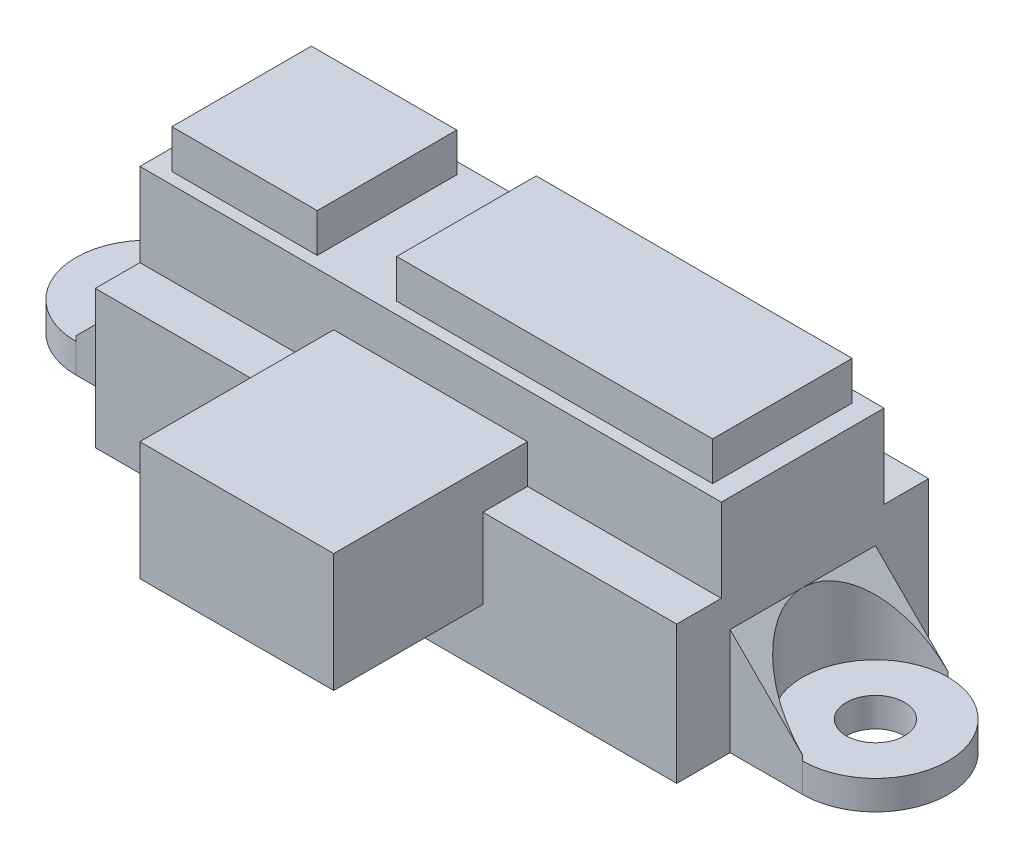
from build123d import *

# Parameters (mm, degrees)
SKETCH1_W            = 30
SKETCH1_H            = 13
BOTTOMPLATEAU_DEPTH  = 7.12
SKETCH3_R            = 1.5
SCREWSOCKETS_DEPTH   = 1.5
SKETCH4_W            = 30
SKETCH4_H            = 8.4
TOPPLATEAU_DEPTH     = 4.3
SKETCH5_W            = 7.5
SKETCH5_H            = 7.2
SKETCH5_W_2          = 16.3
SENSORSOCKETS_DEPTH  = 2
EXTRUDEDSLANTS_DEPTH = 4
F_45SLANTS_DEPTH     = 7.5
CONNECTION_W         = 10
CONNECTION_H         = 6.12
BOSS_EXTRUDE6_DEPTH  = 10


with BuildPart() as part:
    # Sketch1 → BottomPlateau (new body)
    with BuildSketch(Plane(origin=(0, 0, 0), x_dir=(1, 0, 0), z_dir=(0, 1, 0))):
        Rectangle(SKETCH1_W, SKETCH1_H)
    extrude(amount=BOTTOMPLATEAU_DEPTH)

    # Sketch3 → ScrewSockets (add)
    with BuildSketch(Plane.XZ):
        with BuildLine():
            Line((-18.75, 3.75), (-15, 3.75))
            Line((-15, 3.75), (-15, -3.75))
            Line((-15, -3.75), (-18.75, -3.75))
            ThreePointArc((-18.75, -3.75), (-22.5, 0), (-18.75, 3.75))
        make_face()
        with Locations((-18.75, 0)):
            Circle(SKETCH3_R, mode=Mode.SUBTRACT)
        with BuildLine():
            Line((18.75, 3.75), (15, 3.75))
            Line((15, 3.75), (15, -3.75))
            Line((15, -3.75), (18.75, -3.75))
            ThreePointArc((18.75, -3.75), (22.5, 0), (18.75, 3.75))
        make_face()
        with Locations((18.75, 0)):
            Circle(SKETCH3_R, mode=Mode.SUBTRACT)
    extrude(amount=-SCREWSOCKETS_DEPTH)

    # Sketch4 → TopPlateau (add)
    with BuildSketch(Plane(origin=(0, 7.12, 0), x_dir=(1, 0, 0), z_dir=(0, 1, 0))):
        Rectangle(SKETCH4_W, SKETCH4_H)
    extrude(amount=TOPPLATEAU_DEPTH)

    # Sketch5 → SensorSockets (add)
    with BuildSketch(Plane(origin=(0, 11.42, 0), x_dir=(1, 0, 0), z_dir=(0, 1, 0))):
        with Locations((-10.2, 0)):
            Rectangle(SKETCH5_W, SKETCH5_H)
        with Locations((5.8, 0)):
            Rectangle(SKETCH5_W_2, SKETCH5_H)
    extrude(amount=SENSORSOCKETS_DEPTH)

    # Sketch6 → ExtrudedSlants (add)
    with BuildSketch(Plane(origin=(0, 1.5, 0), x_dir=(1, 0, 0), z_dir=(0, 1, 0))):
        with BuildLine():
            Line((-15, -3.75), (-15, 0))
            ThreePointArc((-15, 0), (-16.098349571, -2.651650429), (-18.75, -3.75))
            Line((-18.75, -3.75), (-15, -3.75))
        make_face()
        with BuildLine():
            Line((-15, 3.75), (-18.75, 3.75))
            ThreePointArc((-18.75, 3.75), (-16.098349571, 2.651650429), (-15, 0))
            Line((-15, 0), (-15, 3.75))
        make_face()
        with BuildLine():
            ThreePointArc((15, 6e-09), (16.098349573, 2.651650432), (18.75, 3.75))
            Line((18.75, 3.75), (15, 3.75))
            Line((15, 3.75), (15, 6e-09))
        make_face()
        with BuildLine():
            ThreePointArc((18.75, -3.75), (16.098349568, -2.651650427), (15, 6e-09))
            Line((15, 6e-09), (15, -3.75))
            Line((15, -3.75), (18.75, -3.75))
        make_face()
    extrude(amount=EXTRUDEDSLANTS_DEPTH)

    # Sketch7 → 45Slants (cut)
    with BuildSketch(Plane.XY.offset(3.75)):
        Polygon((-15, 5.5), (-18.75, 1.75), (-18.75, 5.5), align=None)
        Polygon((15, 5.5), (18.75, 1.75), (18.75, 5.5), align=None)
    extrude(amount=-F_45SLANTS_DEPTH, mode=Mode.SUBTRACT)

    # Connection → Boss-Extrude6 (add)
    with BuildSketch(Plane.XY.offset(4.2)):
        with Locations((0, 6.06)):
            Rectangle(CONNECTION_W, CONNECTION_H)
    extrude(amount=BOSS_EXTRUDE6_DEPTH)


solid = part.part
